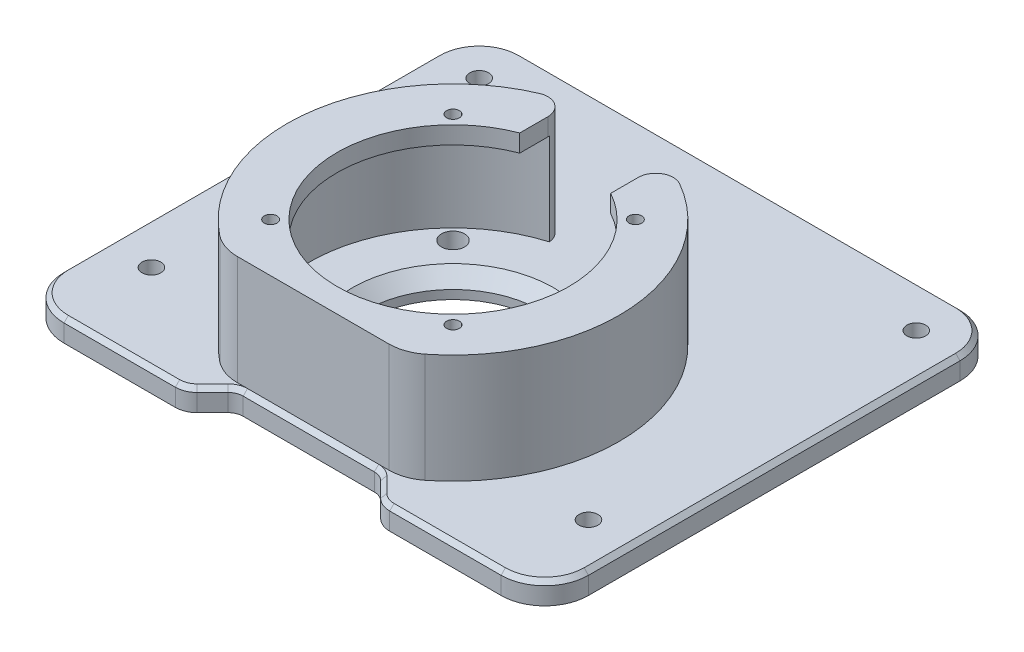
from build123d import *

# Parameters (mm, degrees)
SKETCH2_W           = 120
SKETCH2_H           = 105
BOSS_EXTRUDE2_DEPTH = 5
CUT_EXTRUDE7_DEPTH  = 6
FILLET5_R           = 10
SKETCH10_R          = 20
CUT_EXTRUDE9_DEPTH  = 6
CHAMFER3_SIZE       = 3
FILLET6_R           = 5
CHAMFER4_SIZE       = 1
SKETCH11_R          = 2.15
CUT_EXTRUDE10_DEPTH = 6
BOSS_EXTRUDE3_DEPTH = 25
BOSS_EXTRUDE4_START = -25
SKETCH27_3_R        = 1.45
BOSS_EXTRUDE4_DEPTH = 4
SKETCH28_R          = 2.625
CUT_EXTRUDE13_DEPTH = 5
FILLET7_R           = 10
FILLET8_R           = 4


with BuildPart() as part:
    # Sketch2 → Boss-Extrude2 (new body)
    with BuildSketch(Plane(origin=(0, 0, 0), x_dir=(1, 0, 0), z_dir=(0, 1, 0))):
        with Locations((0, 13.5)):
            Rectangle(SKETCH2_W, SKETCH2_H)
    extrude(amount=BOSS_EXTRUDE2_DEPTH)

    # Sketch9 → Cut-Extrude7 (cut, through all)
    with BuildSketch(Plane(origin=(0, 5, 0), x_dir=(1, 0, 0), z_dir=(0, 1, 0))):
        with BuildLine():
            Line((-17.474873734, -34.025126266), (-23.449747468, -40))
            Line((-23.449747468, -40), (23.449747468, -40))
            Line((23.449747468, -40), (17.474873734, -34.025126266))
            ThreePointArc((17.474873734, -34.025126266), (16.339392013, -33.266421636), (15, -33))
            Line((15, -33), (-15, -33))
            ThreePointArc((-15, -33), (-16.339392013, -33.266421636), (-17.474873734, -34.025126266))
        make_face()
    extrude(amount=-CUT_EXTRUDE7_DEPTH, mode=Mode.SUBTRACT)

    # Fillet5
    fillet5_edges = [part.edges().sort_by_distance(p)[0] for p in [
        (-60, 2.5, -66),
        (60, 2.5, -66),
        (60, 2.5, 39),
        (-60, 2.5, 39),
    ]]
    fillet(fillet5_edges, radius=FILLET5_R)

    # Sketch10 → Cut-Extrude9 (cut, through all)
    with BuildSketch(Plane(origin=(0, 0, 0), x_dir=(1, 0, 0), z_dir=(0, 1, 0))):
        Circle(SKETCH10_R)
    extrude(amount=CUT_EXTRUDE9_DEPTH, mode=Mode.SUBTRACT)

    # Chamfer3
    chamfer3_edges = [part.edges().sort_by_distance(p)[0] for p in [
        (-20, 5, 0),
    ]]
    chamfer(chamfer3_edges, length=CHAMFER3_SIZE)

    # Fillet6
    fillet6_edges = [part.edges().sort_by_distance(p)[0] for p in [
        (22.449747468, 2.5, 39),
        (-22.449747468, 2.5, 39),
    ]]
    fillet(fillet6_edges, radius=FILLET6_R)

    # Chamfer4
    chamfer4_edges = [part.edges().sort_by_distance(p)[0] for p in [
        (16.339392013, 5, 33.266421636),
        (0, 5, 33),
        (-16.339392013, 5, 33.266421636),
        (-19.230077554, 5, 35.780330086),
        (-60, 5, -13.5),
        (0, 5, -66),
        (60, 5, -13.5),
        (-37.26040764, 5, 39),
        (-57.071067812, 5, 36.071067812),
        (57.071067812, 5, 36.071067812),
        (57.071067812, 5, -63.071067812),
        (-57.071067812, 5, -63.071067812),
        (19.230077554, 5, 35.780330086),
        (37.26040764, 5, 39),
        (22.607398118, 5, 38.619397663),
        (-22.607398118, 5, 38.619397663),
    ]]
    chamfer(chamfer4_edges, length=CHAMFER4_SIZE)

    # Sketch11 → Cut-Extrude10 (cut, through all)
    with BuildSketch(Plane(origin=(0, 5, 0), x_dir=(1, 0, 0), z_dir=(0, 1, 0))):
        with Locations((-50, 56)):
            Circle(SKETCH11_R)
        with Locations((50, 56)):
            Circle(SKETCH11_R)
        with Locations((-50, -19)):
            Circle(SKETCH11_R)
        with Locations((50, -19)):
            Circle(SKETCH11_R)
    extrude(amount=-CUT_EXTRUDE10_DEPTH, mode=Mode.SUBTRACT)

    # Sketch27 → Boss-Extrude3 (add)
    with BuildSketch(Plane.XZ.offset(-5)):
        with BuildLine():
            Line((15, 32), (-15, 32))
            Line((-15, 32), (-20.493901532, 32))
            ThreePointArc((-20.493901532, 32), (-37.525010245, -5.989457917), (-9.514215685, -36.789668385))
            Line((-9.514215685, -36.789668385), (-9.514215685, -31.598729403))
            ThreePointArc((-9.514215685, -31.598729403), (-32.683633122, -4.55852234), (-17.797335541, 27.789473684))
            Line((-17.797335541, 27.789473684), (17.797335541, 27.789473684))
            ThreePointArc((17.797335541, 27.789473684), (32.881527048, -2.793775048), (12.853805326, -30.393744235))
            Line((12.853805326, -30.393744235), (12.853805326, -35.760029204))
            ThreePointArc((12.853805326, -35.760029204), (37.760730628, -4.257607592), (20.493901532, 32))
            Line((20.493901532, 32), (15, 32))
        make_face()
    extrude(amount=-BOSS_EXTRUDE3_DEPTH)

    # Sketch27_3 → Boss-Extrude4 (add)
    with BuildSketch(Plane.XZ.offset(-5).offset(BOSS_EXTRUDE4_START)):
        with BuildLine():
            ThreePointArc((-17.797335541, 27.789473684), (-32.683633122, -4.55852234), (-9.514215685, -31.598729403))
            Line((-9.514215685, -31.598729403), (-9.514215685, -24.786250802))
            ThreePointArc((-9.514215685, -24.786250802), (-1.842083043, 26.485566994), (12.853805326, -23.230544926))
            Line((12.853805326, -23.230544926), (12.853805326, -30.393744235))
            ThreePointArc((12.853805326, -30.393744235), (32.881527048, -2.793775048), (17.797335541, 27.789473684))
            Line((17.797335541, 27.789473684), (-17.797335541, 27.789473684))
        make_face()
        with Locations((-20.859650045, -20.859650045)):
            Circle(SKETCH27_3_R, mode=Mode.SUBTRACT)
        with Locations((20.859650045, -20.859650045)):
            Circle(SKETCH27_3_R, mode=Mode.SUBTRACT)
        with Locations((-20.859650045, 20.859650045)):
            Circle(SKETCH27_3_R, mode=Mode.SUBTRACT)
        with Locations((20.859650045, 20.859650045)):
            Circle(SKETCH27_3_R, mode=Mode.SUBTRACT)
    extrude(amount=BOSS_EXTRUDE4_DEPTH)

    # Sketch28 → Cut-Extrude13 (cut)
    with BuildSketch(Plane.XZ):
        with Locations((-20.859650045, 20.859650045)):
            Circle(SKETCH28_R)
        with Locations((20.859650045, 20.859650045)):
            Circle(SKETCH28_R)
        with Locations((20.859650045, -20.859650045)):
            Circle(SKETCH28_R)
        with Locations((-20.859650045, -20.859650045)):
            Circle(SKETCH28_R)
    extrude(amount=-CUT_EXTRUDE13_DEPTH, mode=Mode.SUBTRACT)

    # Fillet7
    fillet7_edges = [part.edges().sort_by_distance(p)[0] for p in [
        (-20.493901532, 17.5, 32),
        (20.493901532, 17.5, 32),
    ]]
    fillet(fillet7_edges, radius=FILLET7_R)

    # Fillet8
    fillet8_edges = [part.edges().sort_by_distance(p)[0] for p in [
        (-9.514215685, 17.5, -36.789668385),
        (12.853805326, 17.5, -35.760029204),
    ]]
    fillet(fillet8_edges, radius=FILLET8_R)


solid = part.part
